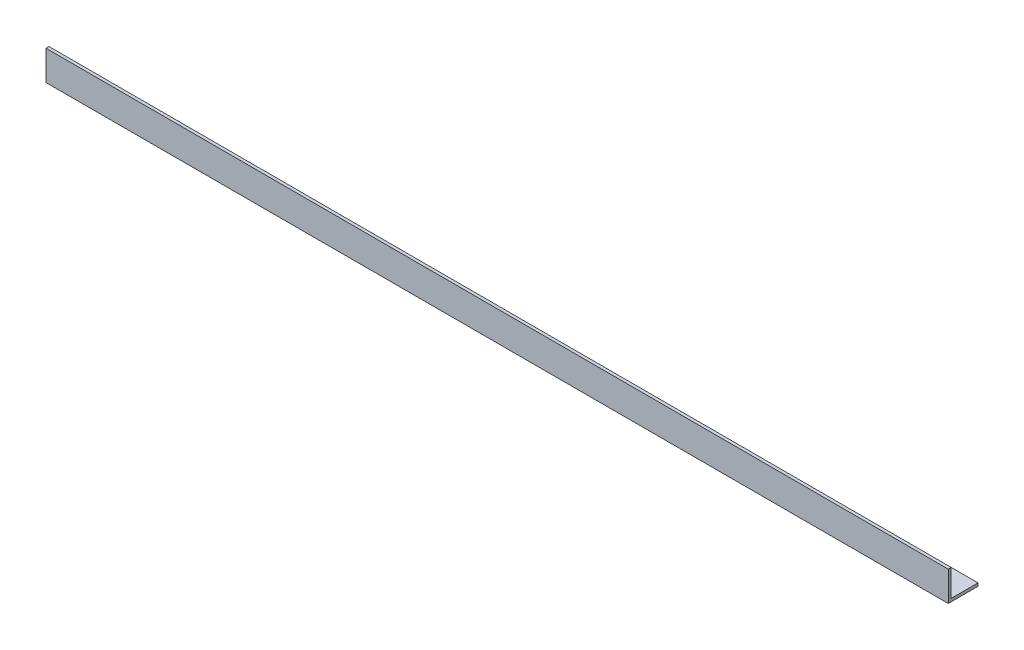
from build123d import *

# Parameters (mm, degrees)
EXTRUDE_1_DEPTH = 455


with BuildPart() as part:
    # Эскиз1 → Бобышка-Вытянуть1 (new body)
    with BuildSketch(Plane(origin=(0, 0, 0), x_dir=(0, 0, -1), z_dir=(1, 0, 0))):
        Polygon((0, 0), (0, 15), (1.5, 15), (1.5, 1.5), (15, 1.5), (15, 0), align=None)
    extrude(amount=EXTRUDE_1_DEPTH)


solid = part.part
